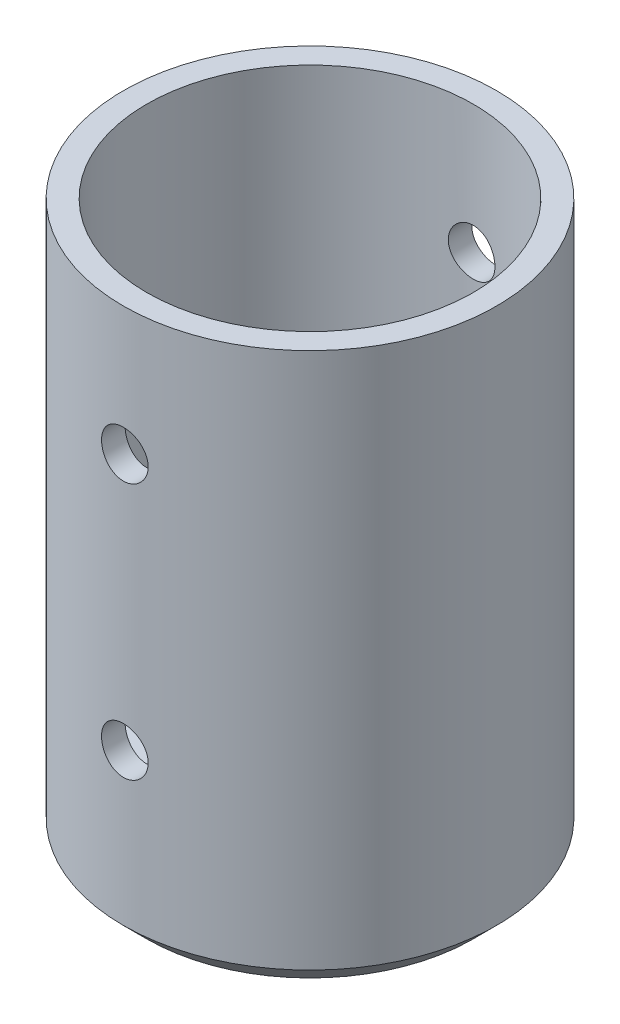
from build123d import *

# Parameters (mm, degrees)
SKETCH1_R           = 25.4
BOSS_EXTRUDE1_DEPTH = 76.2
SKETCH2_R           = 22.225
CUT_EXTRUDE1_DEPTH  = 69.85
CHAMFER1_SIZE       = 3.175
SKETCH3_R           = 1.5875
CUT_EXTRUDE2_DEPTH  = 63.5
SKETCH6_R           = 3.175
CUT_EXTRUDE3_DEPTH  = 51.8


with BuildPart() as part:
    # Sketch1 → Boss-Extrude1 (new body)
    with BuildSketch(Plane(origin=(0, 0, 0), x_dir=(1, 0, 0), z_dir=(0, 1, 0))):
        Circle(SKETCH1_R)
    extrude(amount=BOSS_EXTRUDE1_DEPTH)

    # Sketch2 → Cut-Extrude1 (cut)
    with BuildSketch(Plane(origin=(0, 76.2, 0), x_dir=(1, 0, 0), z_dir=(0, 1, 0))):
        Circle(SKETCH2_R)
    extrude(amount=-CUT_EXTRUDE1_DEPTH, mode=Mode.SUBTRACT)

    # Chamfer1
    chamfer1_edges = [part.edges().sort_by_distance(p)[0] for p in [
        (-25.4, 0, 0),
    ]]
    chamfer(chamfer1_edges, length=CHAMFER1_SIZE)

    # Sketch3 → Cut-Extrude2 (cut)
    with BuildSketch(Plane(origin=(0, 6.35, 0), x_dir=(1, 0, 0), z_dir=(0, 1, 0))):
        with Locations((-12.7, 0)):
            Circle(SKETCH3_R)
        with Locations((12.7, 0)):
            Circle(SKETCH3_R)
    extrude(amount=-CUT_EXTRUDE2_DEPTH, mode=Mode.SUBTRACT)

    # Sketch6 → Cut-Extrude3 (cut, through all)
    with BuildSketch(Plane.XY.offset(25.4)):
        with Locations((0, 23.8125)):
            Circle(SKETCH6_R)
        with Locations((0, 58.7375)):
            Circle(SKETCH6_R)
    extrude(amount=-CUT_EXTRUDE3_DEPTH, mode=Mode.SUBTRACT)


solid = part.part
